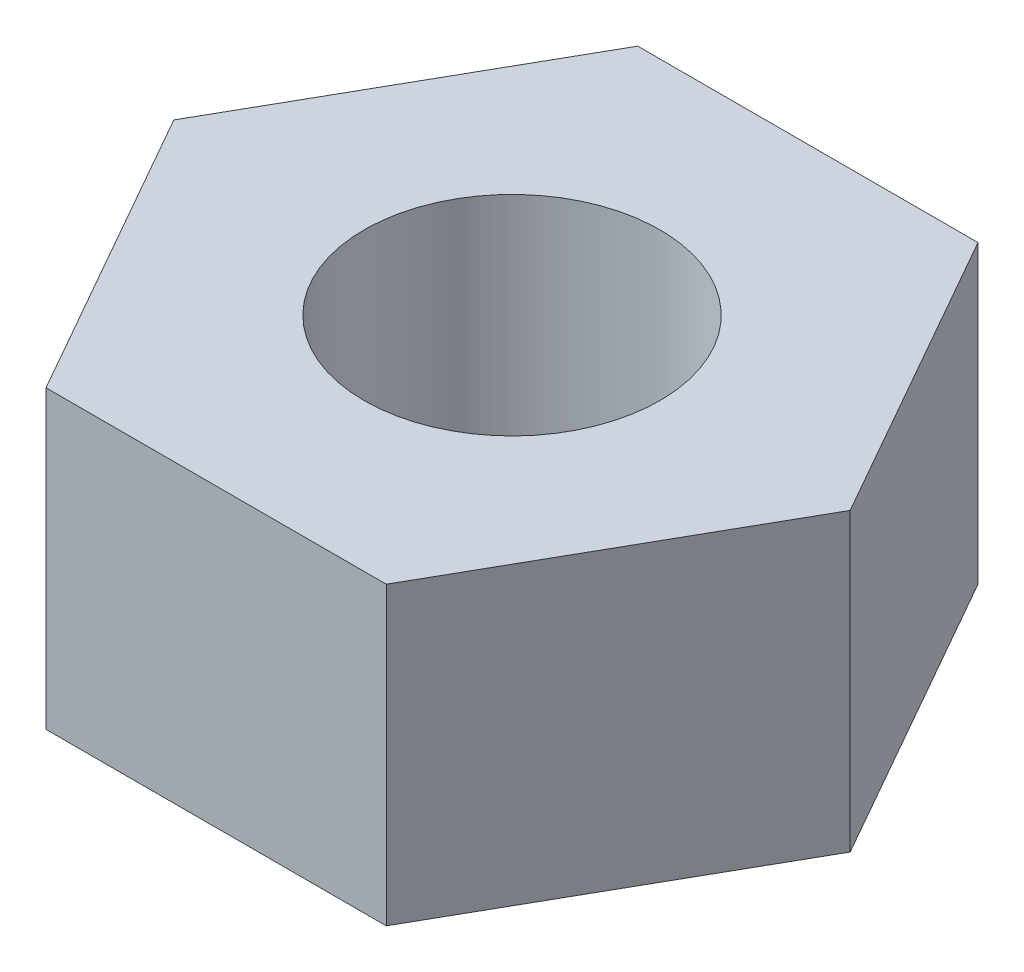
from build123d import *

# Parameters (mm, degrees)
SKETCH1_R           = 5
BOSS_EXTRUDE1_DEPTH = 10


with BuildPart() as part:
    # Sketch1 → Boss-Extrude1 (new body)
    with BuildSketch(Plane(origin=(0, 0, 0), x_dir=(1, 0, 0), z_dir=(0, 1, 0))):
        Polygon((-5.751091654, 10), (5.748908346, 10), (11.427816692, 0), (5.748908346, -10), (-5.751091654, -10), (-11.43, 0), align=None)
        Circle(SKETCH1_R, mode=Mode.SUBTRACT)
    extrude(amount=BOSS_EXTRUDE1_DEPTH)


solid = part.part
